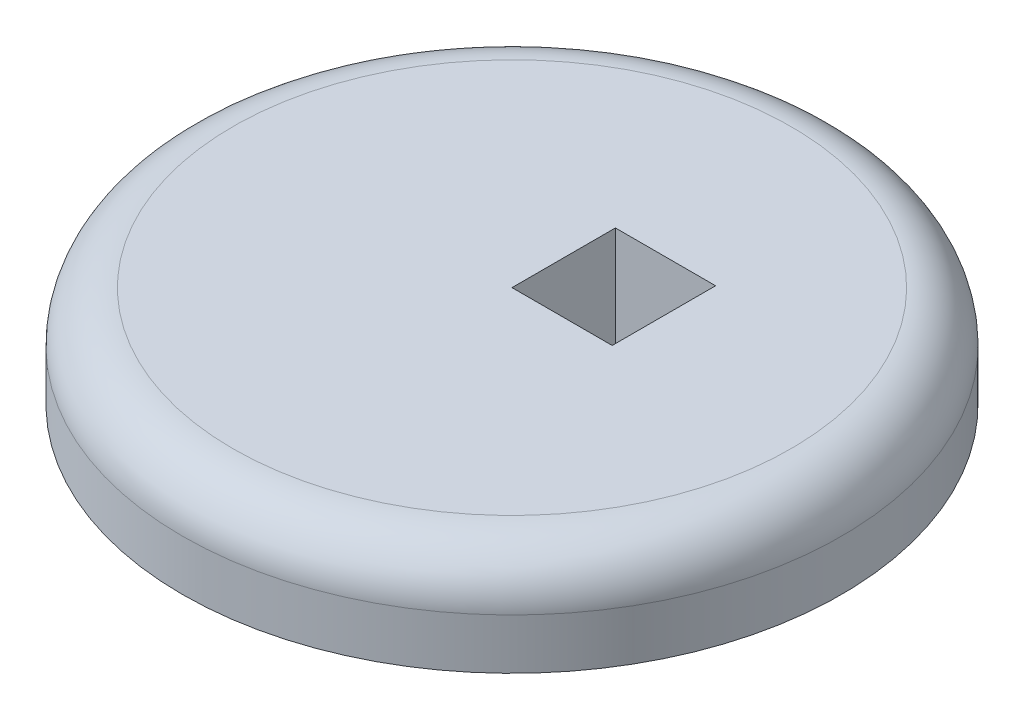
from build123d import *

# Parameters (mm, degrees)
SKETCH1_R           = 32.625062454
BOSS_EXTRUDE1_DEPTH = 10
FILLET1_R           = 5
SKETCH2_W           = 9.918534818
SKETCH2_H           = 10.237019881
CUT_EXTRUDE1_DEPTH  = 10


with BuildPart() as part:
    # Sketch1 → Boss-Extrude1 (new body)
    with BuildSketch(Plane(origin=(0, 0, 0), x_dir=(1, 0, 0), z_dir=(0, 1, 0))):
        with Locations(Location((0, 0, 0), (0, 0, 270))):  # turned: the seam where the file's is
            Circle(SKETCH1_R)
    extrude(amount=BOSS_EXTRUDE1_DEPTH)

    # Fillet1
    fillet1_edges = [part.edges().sort_by_distance(p)[0] for p in [
        (0, 10, -32.625062454),
    ]]
    fillet(fillet1_edges, radius=FILLET1_R)

    # Sketch2 → Cut-Extrude1 (cut)
    with BuildSketch(Plane(origin=(0, 10, 0), x_dir=(1, 0, 0), z_dir=(0, 1, 0))):
        with Locations((4.959267409, 5.118509941)):
            Rectangle(SKETCH2_W, SKETCH2_H)
    extrude(amount=-CUT_EXTRUDE1_DEPTH, mode=Mode.SUBTRACT)


solid = part.part
